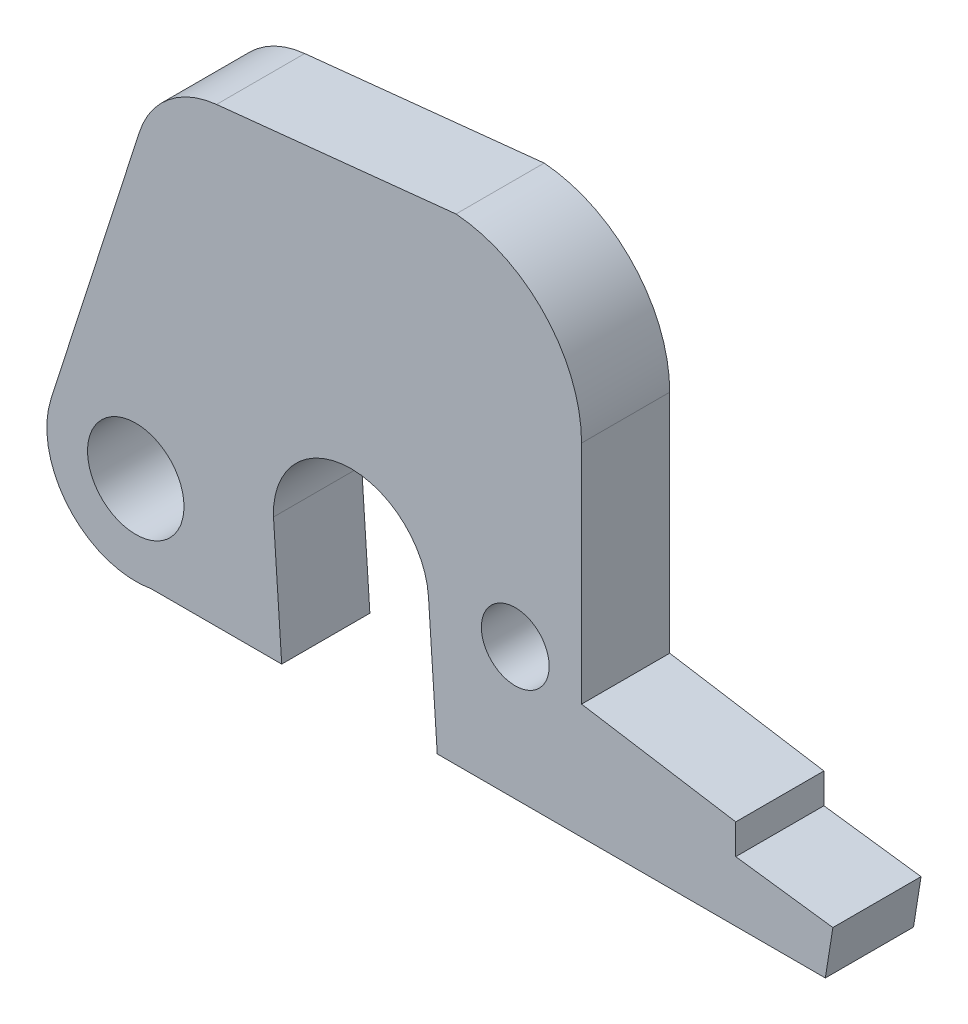
from build123d import *

# Parameters (mm, degrees)
SKETCH2_R           = 1.6256
SKETCH2_R_2         = 1.143
BOSS_EXTRUDE1_DEPTH = 1.4859


with BuildPart() as part:
    # Sketch2 → Boss-Extrude1 (new body, symmetric)
    with BuildSketch(Plane.XY):
        with BuildLine():
            Line((1.669588526, -9.920736917), (14.750588526, -9.920736917))
            Line((14.750588526, -9.920736917), (15.004588526, -8.320536917))
            Line((15.004588526, -8.320536917), (11.730740811, -7.888736917))
            Line((11.730740811, -7.888736917), (11.730740811, -6.872736917))
            Line((11.730740811, -6.872736917), (6.533907217, -6.034536917))
            Line((6.533907217, -6.034536917), (6.533907217, 1.585463083))
            ThreePointArc((6.533907217, 1.585463083), (5.31342025, 4.700559773), (2.301635303, 6.157463083))
            Line((2.301635303, 6.157463083), (-5.77059015, 5.319263083))
            ThreePointArc((-5.77059015, 5.319263083), (-7.384864751, 4.650807821), (-8.371334953, 3.208728953))
            Line((-8.371334953, 3.208728953), (-11.346598434, -6.053267424))
            ThreePointArc((-11.346598434, -6.053267424), (-10.750121538, -8.941908183), (-7.96769015, -9.920736917))
            Line((-7.96769015, -9.920736917), (-3.57349015, -9.920736917))
            Line((-3.57349015, -9.920736917), (-3.850300754, -5.764344341))
            ThreePointArc((-3.850300754, -5.764344341), (-1.375609273, -3.046929144), (1.374211357, -5.485561912))
            Line((1.374211357, -5.485561912), (1.669588526, -9.920736917))
        make_face()
        with Locations((-8.493016303, -6.96993359)):
            Circle(SKETCH2_R, mode=Mode.SUBTRACT)
        with Locations((4.298707217, -5.475736917)):
            Circle(SKETCH2_R_2, mode=Mode.SUBTRACT)
    extrude(amount=BOSS_EXTRUDE1_DEPTH, both=True)


solid = part.part
